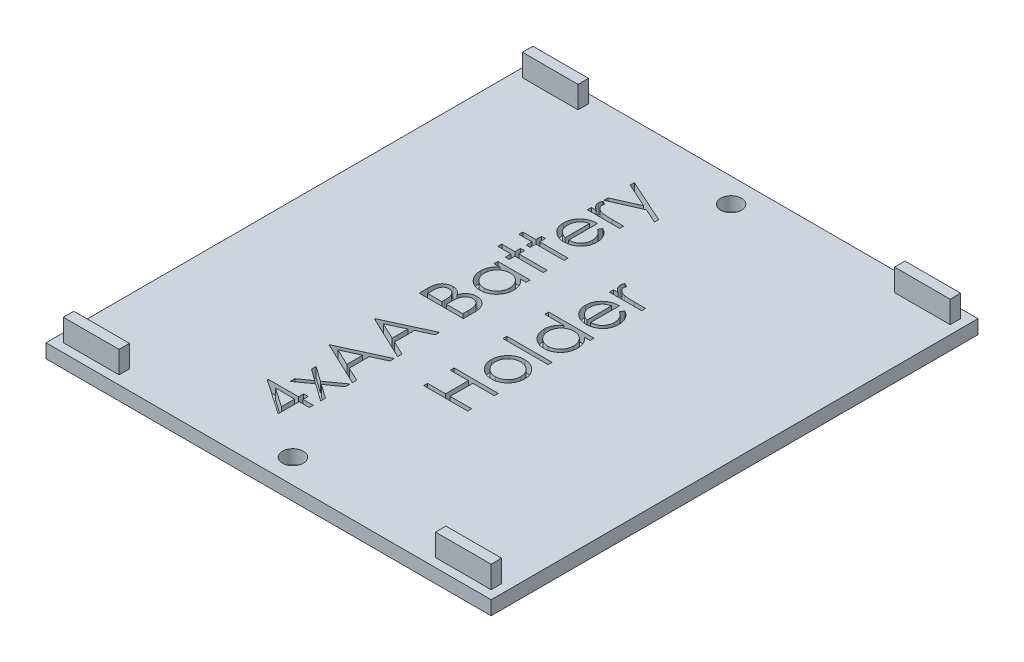
from build123d import *

# Parameters (mm, degrees)
SKETCH1_W               = 64
SKETCH1_H               = 70
BASE_DEPTH              = 2
SKETCH2_W               = 8
SKETCH2_H               = 1.5
BOSS_EXTRUDE2_DEPTH     = 3.175
MIRROR3_COPY_1_SKETCH_W = 8
MIRROR3_COPY_1_SKETCH_H = 1.5
MIRROR3_COPY_1_DEPTH    = 3.175
MIRROR3_COPY_2_SKETCH_W = 8
MIRROR3_COPY_2_SKETCH_H = 1.5
MIRROR3_COPY_2_DEPTH    = 3.175
SKETCH4_W               = 6.512820513
SKETCH4_H               = 0.569871795
LETTERS_DEPTH           = 1.5
SKETCH7_R               = 1.5
CUT_EXTRUDE3_DEPTH      = 48.529786854


with BuildPart() as part:
    # Sketch1 → Base (new body)
    with BuildSketch(Plane(origin=(0, 0, 0), x_dir=(1, 0, 0), z_dir=(0, 1, 0))):
        Rectangle(SKETCH1_W, SKETCH1_H)
    extrude(amount=BASE_DEPTH)

    # Sketch2 → Boss-Extrude2 (add)
    with BuildSketch(Plane(origin=(0, 2, 0), x_dir=(1, 0, 0), z_dir=(0, 1, 0))):
        with Locations((-26.75, 33)):
            Rectangle(SKETCH2_W, SKETCH2_H)
    boss_extrude2 = extrude(amount=BOSS_EXTRUDE2_DEPTH)

    # Mirror2: Boss-Extrude2 across plane
    add(boss_extrude2.mirror(Plane.XY))

    # Mirror3 copy 1 sketch → Mirror3 copy 1 (add)
    with BuildSketch(Plane(origin=(0, 2, 0), x_dir=(-1, 0, 0), z_dir=(0, 1, 0))):
        with Locations((-26.75, 33)):
            Rectangle(MIRROR3_COPY_1_SKETCH_W, MIRROR3_COPY_1_SKETCH_H)
    extrude(amount=MIRROR3_COPY_1_DEPTH)

    # Mirror3 copy 2 sketch → Mirror3 copy 2 (add)
    with BuildSketch(Plane(origin=(0, 2, 0), x_dir=(-1, 0, 0), z_dir=(0, 1, 0))):
        with Locations((-26.75, -33)):
            Rectangle(MIRROR3_COPY_2_SKETCH_W, MIRROR3_COPY_2_SKETCH_H)
    extrude(amount=MIRROR3_COPY_2_DEPTH)

    # Sketch4 → Letters (cut)
    # profile 1 of 17: a face of its own
    with BuildSketch(Plane(origin=(-14.943623663, 2, 1.769971189), x_dir=(1, 0, 0), z_dir=(0, 1, 0))):
        Polygon((3.43080315, -21.914053251), (3.43080315, -21.798298042), (7.826956997, -21.798298042), (7.826956997, -21.065605735), (8.478239048, -21.065605735), (8.478239048, -21.798298042), (9.943623663, -21.798298042), (9.943623663, -22.368169837), (8.478239048, -22.368169837), (8.478239048, -25.380349324), align=None)
        Polygon((7.826956997, -22.368169837), (5.069184561, -22.368169837), (7.826956997, -24.260958299), align=None, mode=Mode.SUBTRACT)
    # profile 2 of 17: a face of its own
    with BuildSketch(Plane(origin=(-14.943623663, 2, 1.769971189), x_dir=(1, 0, 0), z_dir=(0, 1, 0))):
        Polygon((5.303239048, -20.49573394), (5.303239048, -19.817739148), (6.977237445, -18.623298042), (5.303239048, -17.428856936), (5.303239048, -16.750862145), (7.451706596, -18.283664629), (9.943623663, -16.506631376), (9.943623663, -17.184626167), (7.927447782, -18.623298042), (9.943623663, -20.061969917), (9.943623663, -20.739964709), (7.451706596, -18.96165942), align=None)
    # profile 3 of 17: a face of its own
    with BuildSketch(Plane(origin=(-14.943623663, 2, 1.769971189), x_dir=(1, 0, 0), z_dir=(0, 1, 0))):
        Polygon((3.593623663, -13.087400606), (9.943623663, -10.156631376), (9.943623663, -10.776112545), (7.908367253, -11.714874565), (7.908367253, -14.59349035), (9.943623663, -15.55896511), (9.943623663, -16.18099035), (3.593623663, -13.168810863), align=None)
        Polygon((4.831313968, -13.134465911), (7.257085202, -14.284385783), (7.257085202, -12.015074885), align=None, mode=Mode.SUBTRACT)
    # profile 4 of 17: a face of its own
    with BuildSketch(Plane(origin=(-14.943623663, 2, 1.769971189), x_dir=(1, 0, 0), z_dir=(0, 1, 0))):
        Polygon((3.593623663, -6.574580093), (9.943623663, -3.643810863), (9.943623663, -4.263292033), (7.908367253, -5.202054052), (7.908367253, -8.080669837), (9.943623663, -9.046144597), (9.943623663, -9.668169837), (3.593623663, -6.65599035), align=None)
        Polygon((4.831313968, -6.621645398), (7.257085202, -7.77156527), (7.257085202, -5.502254372), align=None, mode=Mode.SUBTRACT)
    # profile 5 of 17: a face of its own
    with BuildSketch(Plane(origin=(-14.943623663, 2, 1.769971189), x_dir=(1, 0, 0), z_dir=(0, 1, 0))):
        with BuildLine():
            Line((3.593623663, -0.224580093), (3.593623663, 1.014382246))
            add(Edge.make_bspline(
                [(3.593623663, 1.014382246), (3.593937505, 1.075032013), (3.594545808, 1.192586356), (3.604199138, 1.363514344), (3.617032327, 1.52366793), (3.638559312, 1.672764102), (3.660879955, 1.811773006), (3.693641316, 1.93928341), (3.729827432, 2.056363373), (3.785504684, 2.196952443), (3.871972157, 2.356470008), (4.000211636, 2.527921542), (4.153960416, 2.676957677), (4.329169279, 2.803682568), (4.521918882, 2.90538199), (4.728062157, 2.978026234), (4.944130988, 3.024695663), (5.09226615, 3.029434985), (5.167131275, 3.031830163)],
                knots=[0, 0, 0, 0, 1.00128172, 1.940733171, 2.826250472, 3.653024905, 4.427672124, 5.149348099, 5.824709082, 6.450061444, 7.643590664, 8.808605388, 9.972104426, 11.165284501, 12.367876273, 13.557044126, 14.765369432, 16, 16, 16, 16], degree=3))
            add(Edge.make_bspline(
                [(5.167131275, 3.031830163), (5.237254972, 3.029835155), (5.375054648, 3.025914776), (5.576255016, 2.988883444), (5.767584804, 2.930109428), (5.948880263, 2.848881366), (6.116766562, 2.744223554), (6.270723634, 2.618828784), (6.40493275, 2.46816797), (6.479934982, 2.355232116), (6.518032718, 2.29786582)],
                knots=[0, 0, 0, 0, 1.044641374, 2.052818814, 3.038628718, 4.023282556, 5.005660861, 5.98021751, 6.974042014, 8, 8, 8, 8], degree=3))
            add(Edge.make_bspline(
                [(6.518032718, 2.29786582), (6.545736755, 2.36999563), (6.598741441, 2.507997825), (6.69230658, 2.698018531), (6.794441874, 2.8611364), (6.904255556, 3.000537857), (7.024368761, 3.119132412), (7.155757354, 3.221842155), (7.298313772, 3.310636729), (7.451514075, 3.386200297), (7.614059515, 3.445556422), (7.78396476, 3.489182351), (7.960578477, 3.514988037), (8.080432082, 3.518508328), (8.141149705, 3.520291701)],
                knots=[0, 0, 0, 0, 1.272586185, 2.434772614, 3.483318042, 4.437947805, 5.351807173, 6.25737843, 7.180033415, 8.1141739, 9.066731021, 10.025721652, 10.999834114, 12, 12, 12, 12], degree=3))
            add(Edge.make_bspline(
                [(8.141149705, 3.520291701), (8.203138425, 3.518519811), (8.325102969, 3.515033567), (8.504269396, 3.489301514), (8.675505755, 3.445762469), (8.839840724, 3.385687144), (8.99692975, 3.307819523), (9.146203753, 3.211687586), (9.287973294, 3.098640832), (9.422488579, 2.970879728), (9.545574294, 2.828499973), (9.6513865, 2.671588318), (9.742369917, 2.50444338), (9.816445371, 2.324928368), (9.873594534, 2.133501548), (9.913411782, 1.930269441), (9.940285601, 1.715566738), (9.942492096, 1.568227968), (9.943623663, 1.492667503)],
                knots=[0, 0, 0, 0, 0.978680899, 1.925582087, 2.851223405, 3.764209995, 4.683484765, 5.614004905, 6.562443559, 7.542772147, 8.539900013, 9.527881485, 10.525548727, 11.540192123, 12.58875426, 13.674701727, 14.807505862, 16, 16, 16, 16], degree=3))
            Line((9.943623663, 1.492667503), (9.943623663, -0.224580093))
            Line((9.943623663, -0.224580093), (3.593623663, -0.224580093))
        make_face()
        with BuildLine():
            Line((4.244905715, 0.345291701), (6.280162125, 0.345291701))
            Line((6.280162125, 0.345291701), (6.280162125, 0.728174314))
            add(Edge.make_bspline(
                [(6.280162125, 0.728174314), (6.27943655, 0.784142842), (6.278034593, 0.892285446), (6.274018639, 1.048894399), (6.262773622, 1.194264081), (6.251531816, 1.328143531), (6.233253688, 1.450322025), (6.211496381, 1.560528548), (6.188486516, 1.660493784), (6.149350985, 1.775769975), (6.091531512, 1.906549207), (6.001713294, 2.045874071), (5.894818274, 2.169270566), (5.770322499, 2.272222394), (5.634724709, 2.3572245), (5.489215326, 2.416771148), (5.336722536, 2.456469125), (5.231833895, 2.460109877), (5.178579593, 2.461958368)],
                knots=[0, 0, 0, 0, 1.156917035, 2.235399477, 3.236897345, 4.169954739, 5.01148057, 5.788325709, 6.491867502, 7.129259015, 8.302032419, 9.437271567, 10.542795419, 11.662606952, 12.764338259, 13.836858145, 14.901724648, 16, 16, 16, 16], degree=3))
            add(Edge.make_bspline(
                [(5.178579593, 2.461958368), (5.143331073, 2.461019818), (5.074187252, 2.45917875), (4.973064059, 2.443552627), (4.878045349, 2.418234161), (4.78821918, 2.383946133), (4.70581795, 2.337103598), (4.626904313, 2.282806946), (4.556204811, 2.215770021), (4.490315694, 2.140012343), (4.431345155, 2.053332047), (4.382497203, 1.953861605), (4.338224729, 1.844172479), (4.305451132, 1.721288744), (4.276631893, 1.587756592), (4.258524571, 1.441767949), (4.246872338, 1.284247913), (4.245575877, 1.175106313), (4.244905715, 1.118689137)],
                knots=[0, 0, 0, 0, 0.911708768, 1.788416306, 2.640049961, 3.452993646, 4.268229297, 5.087074648, 5.92553149, 6.781184137, 7.681934069, 8.628939405, 9.643570426, 10.73771997, 11.914765019, 13.176320755, 14.540391495, 16, 16, 16, 16], degree=3))
            Line((4.244905715, 1.118689137), (4.244905715, 0.345291701))
        make_face(mode=Mode.SUBTRACT)
        with BuildLine():
            Line((6.931444176, 0.345291701), (9.292341612, 0.345291701))
            Line((9.292341612, 0.345291701), (9.292341612, 1.156850195))
            add(Edge.make_bspline(
                [(9.292341612, 1.156850195), (9.291576156, 1.214935599), (9.290100841, 1.326887558), (9.28664092, 1.488654245), (9.273552564, 1.638195702), (9.261478615, 1.775983681), (9.240832681, 1.90165249), (9.221348288, 2.016168782), (9.192425097, 2.117652693), (9.152673574, 2.236412347), (9.089036321, 2.369158191), (8.996062895, 2.514225505), (8.881319334, 2.640721954), (8.750820264, 2.749307347), (8.609319449, 2.838916729), (8.458666742, 2.903219936), (8.301792052, 2.943180243), (8.194804951, 2.948001827), (8.141149705, 2.950419907)],
                knots=[0, 0, 0, 0, 1.160376723, 2.23647316, 3.230273494, 4.158083346, 4.997711197, 5.773399541, 6.476071462, 7.102777513, 8.27340052, 9.405620712, 10.53304798, 11.669441455, 12.787990954, 13.865552736, 14.929550474, 16, 16, 16, 16], degree=3))
            add(Edge.make_bspline(
                [(8.141149705, 2.950419907), (8.107596779, 2.949920508), (8.041032138, 2.948929768), (7.943223973, 2.933920287), (7.848432394, 2.912206324), (7.756262389, 2.883608411), (7.668263675, 2.843630071), (7.584098778, 2.794619976), (7.502072221, 2.738519214), (7.39703011, 2.651966351), (7.277506758, 2.524236404), (7.161931491, 2.342717897), (7.067218679, 2.137464505), (7.027178156, 1.988248325), (7.006494256, 1.911167102)],
                knots=[0, 0, 0, 0, 0.723302347, 1.434937762, 2.129609326, 2.821140842, 3.513216847, 4.209993937, 4.920569932, 5.655069131, 7.14393391, 8.6716197, 10.280644748, 12, 12, 12, 12], degree=3))
            add(Edge.make_bspline(
                [(7.006494256, 1.911167102), (7.000225747, 1.880271457), (6.986634325, 1.813283325), (6.972287492, 1.704049572), (6.95950574, 1.579343067), (6.950051212, 1.438875847), (6.940278483, 1.282470192), (6.936477879, 1.109792068), (6.931943507, 0.921546654), (6.931614877, 0.790931922), (6.931444176, 0.723086173)],
                knots=[0, 0, 0, 0, 0.634451884, 1.375622551, 2.216452059, 3.157844607, 4.20941857, 5.370758133, 6.634282058, 8, 8, 8, 8], degree=3))
            Line((6.931444176, 0.723086173), (6.931444176, 0.345291701))
        make_face(mode=Mode.SUBTRACT)
    # profile 6 of 17: a face of its own
    with BuildSketch(Plane(origin=(-14.943623663, 2, 1.769971189), x_dir=(1, 0, 0), z_dir=(0, 1, 0))):
        with BuildLine():
            Line((5.303239048, 9.381830163), (9.943623663, 9.381830163))
            Line((9.943623663, 9.381830163), (9.943623663, 8.811958368))
            Line((9.943623663, 8.811958368), (9.140969416, 8.811958368))
            add(Edge.make_bspline(
                [(9.140969416, 8.811958368), (9.213492983, 8.747598242), (9.355234107, 8.621811867), (9.542106959, 8.413704558), (9.693422684, 8.190368578), (9.817407586, 7.957408086), (9.910164545, 7.712541172), (9.976211859, 7.457047679), (10.018646129, 7.190683514), (10.022885553, 7.008797974), (10.02503392, 6.916625836)],
                knots=[0, 0, 0, 0, 1.074325654, 2.099677833, 3.090439787, 4.057542011, 5.018572219, 5.985274637, 6.979019747, 8, 8, 8, 8], degree=3))
            add(Edge.make_bspline(
                [(10.02503392, 6.916625836), (10.02280893, 6.834678263), (10.018421152, 6.673074019), (9.984380972, 6.435349837), (9.929715416, 6.20658247), (9.853695231, 5.986555745), (9.75285574, 5.776693424), (9.632130904, 5.575198677), (9.488365398, 5.383115365), (9.324012833, 5.203371287), (9.145496213, 5.037850372), (8.955095007, 4.892596349), (8.753632541, 4.771487189), (8.543659533, 4.670213614), (8.323559608, 4.592205961), (8.094093889, 4.537825225), (7.85553369, 4.5038247), (7.693083412, 4.499438735), (7.610711003, 4.497214778)],
                knots=[0, 0, 0, 0, 1.033919861, 2.038935746, 3.024066025, 3.998881131, 4.97069526, 5.957263378, 6.95902576, 7.993208707, 9.027059324, 10.027763471, 11.009749337, 11.988697705, 12.965288445, 13.950418724, 14.960734635, 16, 16, 16, 16], degree=3))
            add(Edge.make_bspline(
                [(7.610711003, 4.497214778), (7.530041141, 4.499488026), (7.370561175, 4.503982115), (7.13601268, 4.537461528), (6.910100979, 4.593760644), (6.693553382, 4.672768882), (6.486107862, 4.774082143), (6.287617702, 4.897323101), (6.097536081, 5.042500656), (5.92033257, 5.20987288), (5.756646598, 5.391183106), (5.614390187, 5.585146089), (5.491532476, 5.786936899), (5.39418974, 5.999685504), (5.315433222, 6.220242966), (5.260944837, 6.450572789), (5.22883684, 6.689716653), (5.224187253, 6.852077974), (5.221828791, 6.93443433)],
                knots=[0, 0, 0, 0, 1.020392517, 2.01726096, 2.990465484, 3.961182959, 4.928053699, 5.906110375, 6.912531644, 7.948652711, 8.985773172, 9.998621852, 10.987621588, 11.969261332, 12.953316658, 13.946091881, 14.958173133, 16, 16, 16, 16], degree=3))
            add(Edge.make_bspline(
                [(5.221828791, 6.93443433), (5.224440189, 7.029137994), (5.229561017, 7.214847411), (5.272088028, 7.48652216), (5.344153349, 7.743413224), (5.441504795, 7.98824775), (5.573578097, 8.217655653), (5.735521588, 8.434492721), (5.934030582, 8.63414573), (6.084605027, 8.751662182), (6.161862846, 8.811958368)],
                knots=[0, 0, 0, 0, 1.039007978, 2.037445607, 3.008437381, 3.96246474, 4.921201921, 5.904967172, 6.925065498, 8, 8, 8, 8], degree=3))
            Line((6.161862846, 8.811958368), (5.303239048, 8.811958368))
            Line((5.303239048, 8.811958368), (5.303239048, 9.381830163))
        make_face()
        with BuildLine():
            add(Edge.make_bspline(
                [(5.791700586, 6.942066541), (5.794667009, 6.858766607), (5.800522254, 6.694345785), (5.846157483, 6.452940027), (5.922285953, 6.222054541), (6.025791529, 6.002048356), (6.158411712, 5.799056485), (6.314662774, 5.614453935), (6.497182174, 5.453932723), (6.699438066, 5.315884868), (6.917464945, 5.205063312), (7.145304617, 5.126642139), (7.37901403, 5.075017599), (7.537512181, 5.069737132), (7.617071179, 5.067086573)],
                knots=[0, 0, 0, 0, 1.031130969, 2.035288524, 3.029955243, 4.035265425, 5.037320146, 6.024362013, 7.021230137, 8.037832003, 9.049975902, 10.039737725, 11.016035826, 12, 12, 12, 12], degree=3))
            add(Edge.make_bspline(
                [(7.617071179, 5.067086573), (7.696151093, 5.070483677), (7.854000955, 5.077264568), (8.087690308, 5.125511858), (8.315018545, 5.207516707), (8.534797458, 5.318188409), (8.739029616, 5.457860982), (8.924827274, 5.618229528), (9.083522447, 5.803720248), (9.216462346, 6.008526996), (9.323782373, 6.227364682), (9.398473247, 6.457472327), (9.446691717, 6.694556672), (9.45232429, 6.855760003), (9.455162125, 6.9369784)],
                knots=[0, 0, 0, 0, 0.979154007, 1.954470061, 2.941101473, 3.965068436, 4.993389179, 5.998216918, 6.996159742, 8.005560442, 9.015493761, 10.005250788, 10.994993882, 12, 12, 12, 12], degree=3))
            add(Edge.make_bspline(
                [(9.455162125, 6.9369784), (9.452115684, 7.019420106), (9.446056615, 7.183388483), (9.400679576, 7.425780007), (9.32286612, 7.660203795), (9.218292884, 7.885060707), (9.088044227, 8.094329082), (8.935558235, 8.281513704), (8.759437633, 8.441664554), (8.563630344, 8.575001855), (8.350335697, 8.680744849), (8.123478696, 8.758062776), (7.882598867, 8.803268515), (7.717752316, 8.809021699), (7.633607638, 8.811958368)],
                knots=[0, 0, 0, 0, 1.01787422, 2.024450869, 3.03297362, 4.061474925, 5.080076323, 6.069755756, 7.033548292, 8.009625779, 8.9862229, 9.964937832, 10.961217871, 12, 12, 12, 12], degree=3))
            add(Edge.make_bspline(
                [(7.633607638, 8.811958368), (7.569494717, 8.810217277), (7.443300199, 8.806790259), (7.258011703, 8.780609083), (7.0806948, 8.738962288), (6.911163064, 8.680277094), (6.750353822, 8.603185764), (6.597112428, 8.510207674), (6.452235888, 8.399707787), (6.317719173, 8.273464895), (6.195025449, 8.135279456), (6.085507469, 7.989057933), (5.995539267, 7.83306792), (5.921078675, 7.669932725), (5.861825645, 7.499369304), (5.822296544, 7.319989751), (5.795154247, 7.133700732), (5.792863928, 7.006617174), (5.791700586, 6.942066541)],
                knots=[0, 0, 0, 0, 1.050140795, 2.067009409, 3.05949893, 4.030605086, 5.00011959, 5.97591094, 6.962425594, 7.979863591, 8.993523472, 9.986985069, 10.967611495, 11.937549037, 12.921786183, 13.919465291, 14.943216303, 16, 16, 16, 16], degree=3))
        make_face(mode=Mode.SUBTRACT)
    # profile 7 of 17: a face of its own
    with BuildSketch(Plane(origin=(-14.943623663, 2, 1.769971189), x_dir=(1, 0, 0), z_dir=(0, 1, 0))):
        Polygon((3.43080315, 11.25426606), (3.43080315, 11.824137855), (5.303239048, 11.824137855), (5.303239048, 12.638240419), (5.873110843, 12.638240419), (5.873110843, 11.824137855), (9.943623663, 11.824137855), (9.943623663, 11.25426606), (5.873110843, 11.25426606), (5.873110843, 10.440163496), (5.303239048, 10.440163496), (5.303239048, 11.25426606), align=None)
    # profile 8 of 17: a face of its own
    with BuildSketch(Plane(origin=(-14.943623663, 2, 1.769971189), x_dir=(1, 0, 0), z_dir=(0, 1, 0))):
        Polygon((3.43080315, 14.266445548), (3.43080315, 14.836317342), (5.303239048, 14.836317342), (5.303239048, 15.650419907), (5.873110843, 15.650419907), (5.873110843, 14.836317342), (9.943623663, 14.836317342), (9.943623663, 14.266445548), (5.873110843, 14.266445548), (5.873110843, 13.452342983), (5.303239048, 13.452342983), (5.303239048, 14.266445548), align=None)
    # profile 9 of 17: a face of its own
    with BuildSketch(Plane(origin=(-14.943623663, 2, 1.769971189), x_dir=(1, 0, 0), z_dir=(0, 1, 0))):
        with BuildLine():
            Line((8.478239048, 20.517226798), (8.744094416, 21.02349683))
            add(Edge.make_bspline(
                [(8.744094416, 21.02349683), (8.815638925, 20.983132127), (8.954836207, 20.904598402), (9.146087265, 20.770092842), (9.317115506, 20.627801195), (9.465182278, 20.47339409), (9.595943623, 20.311524469), (9.708732595, 20.139117921), (9.805584315, 19.957581698), (9.884945262, 19.764916268), (9.947335425, 19.561352425), (9.993410987, 19.345708948), (10.020130434, 19.116967648), (10.023373372, 18.960325915), (10.02503392, 18.880117423)],
                knots=[0, 0, 0, 0, 1.120611642, 2.180266485, 3.186550691, 4.152466804, 5.095166165, 6.022949561, 6.960161436, 7.899497276, 8.862391909, 9.862399089, 10.905440174, 12, 12, 12, 12], degree=3))
            add(Edge.make_bspline(
                [(10.02503392, 18.880117423), (10.022952616, 18.790959835), (10.018892595, 18.61703921), (9.983890553, 18.363874239), (9.926790699, 18.125514444), (9.847024656, 17.901973184), (9.742835044, 17.69379805), (9.615908699, 17.500574716), (9.466896778, 17.321289207), (9.294511869, 17.161583033), (9.110024079, 17.017830943), (8.917817546, 16.890897019), (8.718557901, 16.785269796), (8.513430696, 16.698035348), (8.302902063, 16.629223898), (8.085766278, 16.580325422), (7.862884348, 16.552397852), (7.712125173, 16.548099058), (7.636151708, 16.545932727)],
                knots=[0, 0, 0, 0, 1.14524686, 2.234044844, 3.276713788, 4.290115724, 5.276966211, 6.260758605, 7.254862358, 8.264742877, 9.274005885, 10.257798278, 11.220590477, 12.167824544, 13.118936889, 14.062732937, 15.023735098, 16, 16, 16, 16], degree=3))
            add(Edge.make_bspline(
                [(7.636151708, 16.545932727), (7.564859659, 16.547854312), (7.423568231, 16.55166264), (7.214443601, 16.575667068), (7.01119198, 16.618208971), (6.813644481, 16.676586016), (6.622131867, 16.751971849), (6.43653758, 16.844196018), (6.257059112, 16.953402189), (6.143841998, 17.037716897), (6.086812766, 17.080187535)],
                knots=[0, 0, 0, 0, 1.024358464, 2.0301432, 3.019427413, 4.004406732, 4.986367066, 5.972626655, 6.978780325, 8, 8, 8, 8], degree=3))
            add(Edge.make_bspline(
                [(6.086812766, 17.080187535), (6.017993899, 17.137615155), (5.882757229, 17.250466769), (5.70668112, 17.443319463), (5.556063061, 17.649331207), (5.433188551, 17.870574231), (5.338678625, 18.106675865), (5.271454965, 18.356418315), (5.229625333, 18.62049186), (5.22446715, 18.801517165), (5.221828791, 18.89410981)],
                knots=[0, 0, 0, 0, 1.030811313, 2.025658015, 2.997072178, 3.962767568, 4.930766827, 5.917075773, 6.934604948, 8, 8, 8, 8], degree=3))
            add(Edge.make_bspline(
                [(5.221828791, 18.89410981), (5.224273119, 18.989270223), (5.229068333, 19.17595326), (5.27392138, 19.448077087), (5.344186372, 19.706071974), (5.446559129, 19.947808821), (5.573457155, 20.177012436), (5.733850318, 20.388407725), (5.919500635, 20.587797624), (6.062422456, 20.703733901), (6.135150106, 20.762729602)],
                knots=[0, 0, 0, 0, 1.056389096, 2.072394598, 3.055233004, 4.020130009, 4.981825462, 5.957811105, 6.960805292, 8, 8, 8, 8], degree=3))
            add(Edge.make_bspline(
                [(6.135150106, 20.762729602), (6.189948032, 20.80287419), (6.299179133, 20.882896152), (6.477289661, 20.983130176), (6.663636025, 21.070138593), (6.861230421, 21.139685536), (7.067731659, 21.19600006), (7.28461599, 21.236743145), (7.51181883, 21.260636596), (7.66662558, 21.265333233), (7.74554674, 21.267727599)],
                knots=[0, 0, 0, 0, 0.94817472, 1.890038105, 2.849395472, 3.817997239, 4.812318967, 5.836947057, 6.897266129, 8, 8, 8, 8], degree=3))
            Line((7.74554674, 21.267727599), (7.74554674, 17.115804522))
            add(Edge.make_bspline(
                [(7.74554674, 17.115804522), (7.806689011, 17.118597808), (7.926922821, 17.124090692), (8.102855527, 17.149699595), (8.270447162, 17.190065227), (8.428440681, 17.246796241), (8.578899627, 17.315497517), (8.720707894, 17.39965446), (8.853219567, 17.500056223), (8.977619945, 17.612044277), (9.088401612, 17.736698579), (9.187555549, 17.867840134), (9.270659989, 18.007347031), (9.338114931, 18.154119268), (9.390922105, 18.307919507), (9.426968008, 18.468796204), (9.451110902, 18.636432786), (9.453795437, 18.750706904), (9.455162125, 18.808883448)],
                knots=[0, 0, 0, 0, 1.094153842, 2.151609401, 3.174256925, 4.172055639, 5.149267565, 6.128595816, 7.11444997, 8.118368179, 9.117203808, 10.09244225, 11.054858984, 12.015122123, 12.976791628, 13.957293641, 14.960065497, 16, 16, 16, 16], degree=3))
            add(Edge.make_bspline(
                [(9.455162125, 18.808883448), (9.45406782, 18.865765869), (9.451896509, 18.978631504), (9.430480609, 19.14667193), (9.396538265, 19.312281418), (9.347650967, 19.473815512), (9.290404601, 19.628920054), (9.223025997, 19.773348842), (9.146206762, 19.905192453), (9.058911323, 20.028898318), (8.951776893, 20.148237328), (8.819368102, 20.268496367), (8.660183165, 20.39459961), (8.54116933, 20.474812876), (8.478239048, 20.517226798)],
                knots=[0, 0, 0, 0, 0.991168677, 1.966668791, 2.94808785, 3.9350306, 4.905702032, 5.828266021, 6.709360349, 7.562606342, 8.463112863, 9.498839253, 10.677475166, 12, 12, 12, 12], degree=3))
        make_face()
        with BuildLine():
            add(Edge.make_bspline(
                [(7.175674945, 20.697855804), (7.100048815, 20.677082109), (6.954871215, 20.637203363), (6.75390558, 20.552274645), (6.574269929, 20.458933184), (6.418949407, 20.346568432), (6.280783152, 20.220499492), (6.161971797, 20.072869714), (6.052465649, 19.910081972), (5.961273096, 19.728893863), (5.886334769, 19.536450543), (5.831231933, 19.336707481), (5.798840835, 19.13133771), (5.794091857, 18.993016192), (5.791700586, 18.923366621)],
                knots=[0, 0, 0, 0, 1.155085888, 2.217389643, 3.210301801, 4.133263417, 5.03575695, 5.95948047, 6.920061569, 7.923798377, 8.943125483, 9.960783337, 10.973185325, 12, 12, 12, 12], degree=3))
            add(Edge.make_bspline(
                [(5.791700586, 18.923366621), (5.792797392, 18.866485437), (5.794965548, 18.754043293), (5.815962612, 18.588459866), (5.849702564, 18.429028905), (5.899311968, 18.276226305), (5.959676808, 18.129038469), (6.033877411, 17.987571752), (6.123587238, 17.853644735), (6.192116106, 17.769940539), (6.226736644, 17.72765348)],
                knots=[0, 0, 0, 0, 1.048823158, 2.073302879, 3.073550078, 4.050623576, 5.03253758, 6.005186856, 6.992227572, 8, 8, 8, 8], degree=3))
            add(Edge.make_bspline(
                [(6.226736644, 17.72765348), (6.254119167, 17.697362351), (6.30953472, 17.636060487), (6.405064062, 17.554236768), (6.50813463, 17.475309189), (6.623245548, 17.405170535), (6.747058724, 17.338514156), (6.880477593, 17.277772912), (7.024065319, 17.222544161), (7.12417164, 17.191540916), (7.175674945, 17.175590179)],
                knots=[0, 0, 0, 0, 0.879905587, 1.780714457, 2.708106151, 3.677566983, 4.684151534, 5.740052498, 6.837288539, 8, 8, 8, 8], degree=3))
            Line((7.175674945, 17.175590179), (7.175674945, 20.697855804))
        make_face(mode=Mode.SUBTRACT)
    # profile 10 of 17: a face of its own
    with BuildSketch(Plane(origin=(-14.943623663, 2, 1.769971189), x_dir=(1, 0, 0), z_dir=(0, 1, 0))):
        with BuildLine():
            Line((5.303239048, 22.244650676), (5.303239048, 22.814522471))
            Line((5.303239048, 22.814522471), (5.986321981, 22.814522471))
            add(Edge.make_bspline(
                [(5.986321981, 22.814522471), (5.922692219, 22.856566585), (5.801000795, 22.936975628), (5.640272101, 23.071250583), (5.505675407, 23.207321239), (5.399777493, 23.348760562), (5.31974453, 23.494181848), (5.263507873, 23.642358839), (5.228633812, 23.793653878), (5.22410017, 23.895572217), (5.221828791, 23.946633849)],
                knots=[0, 0, 0, 0, 1.280091057, 2.448164201, 3.510831157, 4.48793739, 5.405868014, 6.289422536, 7.142991551, 8, 8, 8, 8], degree=3))
            add(Edge.make_bspline(
                [(5.221828791, 23.946633849), (5.223988747, 23.986233041), (5.228432995, 24.067710953), (5.259658349, 24.191050794), (5.309511333, 24.318129629), (5.356392879, 24.400030817), (5.380833199, 24.442727599)],
                knots=[0, 0, 0, 0, 0.901110191, 1.854092781, 2.881294221, 4, 4, 4, 4], degree=3))
            Line((5.380833199, 24.442727599), (5.874382878, 24.129806926))
            add(Edge.make_bspline(
                [(5.874382878, 24.129806926), (5.862154109, 24.102394845), (5.838941566, 24.050361467), (5.811469633, 23.974243897), (5.795293614, 23.9040649), (5.792843027, 23.859354444), (5.791700586, 23.838510852)],
                knots=[0, 0, 0, 0, 1.180555205, 2.24091978, 3.179933427, 4, 4, 4, 4], degree=3))
            add(Edge.make_bspline(
                [(5.791700586, 23.838510852), (5.794724784, 23.79276672), (5.800893271, 23.69946195), (5.850079764, 23.56293453), (5.927264592, 23.42926635), (6.015155291, 23.324131697), (6.099581993, 23.242440101), (6.173473976, 23.183689577), (6.257095864, 23.130960107), (6.347215485, 23.079811122), (6.446094586, 23.032289852), (6.553894475, 22.989822617), (6.669724982, 22.950107577), (6.750264633, 22.927741897), (6.791520298, 22.916285291)],
                knots=[0, 0, 0, 0, 1.125322384, 2.295331465, 3.535939348, 4.916963136, 5.656144286, 6.429838446, 7.238666481, 8.090384391, 8.983239461, 9.940052224, 10.944811494, 12, 12, 12, 12], degree=3))
            add(Edge.make_bspline(
                [(6.791520298, 22.916285291), (6.828306848, 22.907684539), (6.910194857, 22.888538996), (7.046950996, 22.870420826), (7.208419934, 22.851798302), (7.394789248, 22.839080993), (7.606775347, 22.827067798), (7.843463722, 22.820431214), (8.105504914, 22.814733623), (8.288277618, 22.814595101), (8.384108439, 22.814522471)],
                knots=[0, 0, 0, 0, 0.566841273, 1.261806378, 2.068780918, 3.007109044, 4.065315289, 5.256255371, 6.561408263, 8, 8, 8, 8], degree=3))
            Line((8.384108439, 22.814522471), (9.943623663, 22.814522471))
            Line((9.943623663, 22.814522471), (9.943623663, 22.244650676))
            Line((9.943623663, 22.244650676), (5.303239048, 22.244650676))
        make_face()
    # profile 11 of 17: a face of its own
    with BuildSketch(Plane(origin=(-14.943623663, 2, 1.769971189), x_dir=(1, 0, 0), z_dir=(0, 1, 0))):
        Polygon((5.303239048, 24.605548112), (5.303239048, 25.21994114), (8.857305554, 26.790904682), (5.303239048, 28.386036894), (5.303239048, 29.001701958), (11.653239048, 26.152342983), (11.653239048, 25.536677919), (9.548020699, 26.481800115), align=None)
    # profile 12 of 17: a face of its own
    with BuildSketch(Plane(origin=(-14.943623663, 2, 1.769971189), x_dir=(1, 0, 0), z_dir=(0, 1, 0))):
        Polygon((15.421187766, -11.41849035), (15.421187766, -10.848618555), (18.026315971, -10.848618555), (18.026315971, -7.592208299), (15.421187766, -7.592208299), (15.421187766, -7.022336504), (21.771187766, -7.022336504), (21.771187766, -7.592208299), (18.677598022, -7.592208299), (18.677598022, -10.848618555), (21.771187766, -10.848618555), (21.771187766, -11.41849035), align=None)
    # profile 13 of 17: a face of its own
    with BuildSketch(Plane(origin=(-14.943623663, 2, 1.769971189), x_dir=(1, 0, 0), z_dir=(0, 1, 0))):
        with BuildLine():
            add(Edge.make_bspline(
                [(17.049392894, -3.315625767), (17.051246897, -3.228555886), (17.054882142, -3.057833129), (17.093735009, -2.80781025), (17.153148084, -2.569149789), (17.235283632, -2.340937697), (17.345378028, -2.126096704), (17.476749171, -1.921497447), (17.632383305, -1.727700874), (17.7527758, -1.611544806), (17.813886083, -1.552584901)],
                knots=[0, 0, 0, 0, 1.054011418, 2.066658804, 3.057071809, 4.030435133, 4.997543892, 5.974964718, 6.972108034, 8, 8, 8, 8], degree=3))
            add(Edge.make_bspline(
                [(17.813886083, -1.552584901), (17.872331457, -1.501817642), (17.988091127, -1.401265609), (18.175789167, -1.272332091), (18.370171921, -1.161258689), (18.573820643, -1.072244459), (18.784957546, -1.002058774), (19.004308338, -0.952228153), (19.231388596, -0.922588286), (19.385609845, -0.918591474), (19.463715811, -0.916567273)],
                knots=[0, 0, 0, 0, 1.025258237, 2.030674902, 3.01204498, 3.988269485, 4.97094183, 5.956517959, 6.965070386, 8, 8, 8, 8], degree=3))
            add(Edge.make_bspline(
                [(19.463715811, -0.916567273), (19.542274487, -0.918347699), (19.697510094, -0.921865905), (19.926145229, -0.955146466), (20.147841551, -1.006910007), (20.361670895, -1.080990628), (20.568286882, -1.175983198), (20.766787064, -1.291899159), (20.957563077, -1.42955195), (21.138994984, -1.585587773), (21.306210831, -1.758039034), (21.451949263, -1.945121189), (21.576811171, -2.143157793), (21.677388668, -2.354782163), (21.756690553, -2.578061746), (21.812389154, -2.813478141), (21.846065352, -3.060665626), (21.850389835, -3.229443584), (21.852598022, -3.315625767)],
                knots=[0, 0, 0, 0, 0.998656419, 1.973391657, 2.932242238, 3.890759089, 4.846373663, 5.82037756, 6.809684879, 7.83454468, 8.860553229, 9.859544525, 10.845671541, 11.83227036, 12.833544569, 13.85385346, 14.904124723, 16, 16, 16, 16], degree=3))
            add(Edge.make_bspline(
                [(21.852598022, -3.315625767), (21.850382423, -3.402230186), (21.846043061, -3.571849317), (21.812519991, -3.819909313), (21.756716223, -4.055747622), (21.677128057, -4.279319508), (21.576807956, -4.49185373), (21.452326748, -4.691037803), (21.306167609, -4.878271936), (21.139006695, -5.050759679), (20.95756006, -5.20678572), (20.766787847, -5.344441035), (20.568286678, -5.460356341), (20.361670949, -5.555349082), (20.147841536, -5.629429657), (19.926145233, -5.681193211), (19.697510093, -5.714473769), (19.542274486, -5.717991975), (19.463715811, -5.719772401)],
                knots=[0, 0, 0, 0, 1.099876186, 2.154163076, 3.173186993, 4.173200201, 5.163417411, 6.152872554, 7.150605724, 8.17532212, 9.198891216, 10.186952605, 11.159729845, 12.11414092, 13.071450619, 14.029093627, 15.002601286, 16, 16, 16, 16], degree=3))
            add(Edge.make_bspline(
                [(19.463715811, -5.719772401), (19.38603263, -5.717739237), (19.232233282, -5.713713922), (19.005605049, -5.684033605), (18.786925598, -5.63474518), (18.576941672, -5.56358652), (18.373782416, -5.474737528), (18.178686949, -5.364782032), (17.991809071, -5.234601298), (17.876202912, -5.134439908), (17.817702189, -5.083754773)],
                knots=[0, 0, 0, 0, 1.031377469, 2.041950136, 3.029500481, 4.003457997, 4.981637986, 5.969878303, 6.97268806, 8, 8, 8, 8], degree=3))
            add(Edge.make_bspline(
                [(17.817702189, -5.083754773), (17.756061942, -5.024883758), (17.63483555, -4.909103548), (17.479655114, -4.714342285), (17.345550237, -4.510246352), (17.237643389, -4.293031129), (17.152664935, -4.065006515), (17.093581786, -3.825123032), (17.055022128, -3.57425174), (17.051288005, -3.40269357), (17.049392894, -3.315625767)],
                knots=[0, 0, 0, 0, 1.027980169, 2.021703884, 2.998553061, 3.971491411, 4.943284454, 5.930300938, 6.949603206, 8, 8, 8, 8], degree=3))
        make_face()
        with BuildLine():
            add(Edge.make_bspline(
                [(17.619264689, -3.318169837), (17.621014734, -3.379742361), (17.624469646, -3.501297923), (17.650747589, -3.680222025), (17.692380914, -3.852470597), (17.751533999, -4.018370388), (17.827913387, -4.177362097), (17.921727291, -4.329597363), (18.03173216, -4.475526196), (18.157759762, -4.61228535), (18.295416774, -4.737822044), (18.442131896, -4.847473367), (18.595657756, -4.941237058), (18.756225383, -5.01793019), (18.924382252, -5.076748377), (19.099138083, -5.118428061), (19.281020577, -5.14475412), (19.404687936, -5.148166526), (19.467531916, -5.149900606)],
                knots=[0, 0, 0, 0, 1.02155314, 2.01673505, 2.994700672, 3.958461264, 4.934171024, 5.916582427, 6.921469794, 7.962398674, 8.998583302, 10.009097305, 10.997513862, 11.97957236, 12.956600784, 13.948243505, 14.957359924, 16, 16, 16, 16], degree=3))
            add(Edge.make_bspline(
                [(19.467531916, -5.149900606), (19.54872488, -5.146985369), (19.70987773, -5.141199169), (19.947206481, -5.09414524), (20.175047841, -5.015430132), (20.392066142, -4.909136067), (20.592857275, -4.775956213), (20.771875539, -4.619043964), (20.92642694, -4.440083364), (21.054662188, -4.241207714), (21.156552031, -4.026479166), (21.228758744, -3.799228412), (21.275697386, -3.562208867), (21.280362775, -3.400228112), (21.282726227, -3.318169837)],
                knots=[0, 0, 0, 0, 1.016792936, 2.018143844, 3.017858371, 4.030088057, 5.03801393, 6.028138512, 7.003788237, 7.991172063, 8.984598303, 9.972568034, 10.972917682, 12, 12, 12, 12], degree=3))
            add(Edge.make_bspline(
                [(21.282726227, -3.318169837), (21.280349005, -3.236116282), (21.275656433, -3.074144844), (21.228995146, -2.837454623), (21.156235647, -2.610824988), (21.05477678, -2.396319471), (20.925939971, -2.197534347), (20.772748258, -2.017286656), (20.592383128, -1.861714176), (20.391800183, -1.728666064), (20.175384287, -1.620631259), (19.94716443, -1.542284593), (19.70988844, -1.495117544), (19.548728468, -1.489346612), (19.467531916, -1.486439068)],
                knots=[0, 0, 0, 0, 1.02726834, 2.027799167, 3.010890988, 4.004497153, 4.992059811, 5.971914811, 6.958719428, 7.966827853, 8.981595046, 9.981490638, 10.983022906, 12, 12, 12, 12], degree=3))
            add(Edge.make_bspline(
                [(19.467531916, -1.486439068), (19.404687561, -1.48817255), (19.281019464, -1.491583779), (19.099142341, -1.5179184), (18.924366675, -1.559566468), (18.756282748, -1.618500917), (18.595241164, -1.694853383), (18.442581926, -1.790419573), (18.294908661, -1.899623033), (18.158204773, -2.026674304), (18.031683035, -2.163290717), (17.921684633, -2.309278686), (17.828325689, -2.461288214), (17.750880696, -2.619818023), (17.692919081, -2.785739085), (17.650507196, -2.957746312), (17.624580695, -3.135907008), (17.621048024, -3.257026987), (17.619264689, -3.318169837)],
                knots=[0, 0, 0, 0, 1.042975879, 2.052417305, 3.044379404, 4.0217225, 5.00409729, 5.996508862, 7.007348322, 8.048612455, 9.089876587, 10.095087598, 11.077815406, 12.047498138, 13.018202342, 13.98964644, 14.985148868, 16, 16, 16, 16], degree=3))
        make_face(mode=Mode.SUBTRACT)
    # profile 14 of 17: a face of its own
    with BuildSketch(Plane(origin=(-14.943623663, 2, 1.769971189), x_dir=(1, 0, 0), z_dir=(0, 1, 0))):
        with Locations((18.51477751, 0.426701958)):
            Rectangle(SKETCH4_W, SKETCH4_H)
    # profile 15 of 17: a face of its own
    with BuildSketch(Plane(origin=(-14.943623663, 2, 1.769971189), x_dir=(1, 0, 0), z_dir=(0, 1, 0))):
        with BuildLine():
            Line((15.258367253, 6.73599683), (21.771187766, 6.73599683))
            Line((21.771187766, 6.73599683), (21.771187766, 6.166125035))
            Line((21.771187766, 6.166125035), (20.968533519, 6.166125035))
            add(Edge.make_bspline(
                [(20.968533519, 6.166125035), (21.041057086, 6.101764909), (21.182798209, 5.975978533), (21.369671062, 5.767871224), (21.520986787, 5.544535245), (21.644971689, 5.311574752), (21.737728647, 5.066707839), (21.803775961, 4.811214346), (21.846210232, 4.54485018), (21.850449656, 4.362964641), (21.852598022, 4.270792503)],
                knots=[0, 0, 0, 0, 1.074325654, 2.099677833, 3.090439787, 4.057542011, 5.018572219, 5.985274637, 6.979019747, 8, 8, 8, 8], degree=3))
            add(Edge.make_bspline(
                [(21.852598022, 4.270792503), (21.850373033, 4.188844929), (21.845985254, 4.027240686), (21.811945075, 3.789516503), (21.757279519, 3.560749136), (21.681259333, 3.340722412), (21.580419843, 3.130860091), (21.459695007, 2.929365344), (21.315929501, 2.737282031), (21.151576935, 2.557537953), (20.973060316, 2.392017038), (20.782659109, 2.246763015), (20.581196643, 2.125653856), (20.371223636, 2.024380281), (20.15112371, 1.946372628), (19.921657991, 1.891991891), (19.683097792, 1.857991366), (19.520647515, 1.853605402), (19.438275106, 1.851381445)],
                knots=[0, 0, 0, 0, 1.033919861, 2.038935746, 3.024066025, 3.998881131, 4.97069526, 5.957263378, 6.95902576, 7.993208707, 9.027059324, 10.027763471, 11.009749337, 11.988697705, 12.965288445, 13.950418724, 14.960734635, 16, 16, 16, 16], degree=3))
            add(Edge.make_bspline(
                [(19.438275106, 1.851381445), (19.357605243, 1.853654693), (19.198125278, 1.858148782), (18.963576783, 1.891628195), (18.737665081, 1.947927311), (18.521117484, 2.026935549), (18.313671965, 2.12824881), (18.115181805, 2.251489768), (17.925100184, 2.396667322), (17.747896672, 2.564039547), (17.584210701, 2.745349773), (17.44195429, 2.939312756), (17.319096578, 3.141103566), (17.221753843, 3.353852171), (17.142997324, 3.574409633), (17.088508939, 3.804739456), (17.056400942, 4.04388332), (17.051751356, 4.206244641), (17.049392894, 4.288600996)],
                knots=[0, 0, 0, 0, 1.020392517, 2.01726096, 2.990465484, 3.961182959, 4.928053699, 5.906110375, 6.912531644, 7.948652711, 8.985773172, 9.998621852, 10.987621588, 11.969261332, 12.953316658, 13.946091881, 14.958173133, 16, 16, 16, 16], degree=3))
            add(Edge.make_bspline(
                [(17.049392894, 4.288600996), (17.052199807, 4.383347462), (17.057709466, 4.569324245), (17.104841688, 4.841016575), (17.181206883, 5.09868211), (17.288576108, 5.34287146), (17.429501888, 5.571443336), (17.597499484, 5.788192795), (17.799593376, 5.987660987), (17.951272664, 6.105730047), (18.028860041, 6.166125035)],
                knots=[0, 0, 0, 0, 1.030935089, 2.023611011, 2.991955418, 3.950956655, 4.918431382, 5.908366361, 6.930082213, 8, 8, 8, 8], degree=3))
            Line((18.028860041, 6.166125035), (15.258367253, 6.166125035))
            Line((15.258367253, 6.166125035), (15.258367253, 6.73599683))
        make_face()
        with BuildLine():
            add(Edge.make_bspline(
                [(17.619264689, 4.296233208), (17.622231111, 4.212933273), (17.628086357, 4.048512452), (17.673721585, 3.807106694), (17.749850056, 3.576221207), (17.853355632, 3.356215023), (17.985975815, 3.153223152), (18.142226877, 2.968620602), (18.324746276, 2.80809939), (18.527002169, 2.670051535), (18.745029048, 2.559229979), (18.972868719, 2.480808806), (19.206578133, 2.429184265), (19.365076284, 2.423903799), (19.444635282, 2.42125324)],
                knots=[0, 0, 0, 0, 1.031130969, 2.035288524, 3.029955243, 4.035265425, 5.037320146, 6.024362013, 7.021230137, 8.037832003, 9.049975902, 10.039737725, 11.016035826, 12, 12, 12, 12], degree=3))
            add(Edge.make_bspline(
                [(19.444635282, 2.42125324), (19.523715196, 2.424650343), (19.681565057, 2.431431235), (19.91525441, 2.479678524), (20.142582647, 2.561683374), (20.362361561, 2.672355076), (20.566593718, 2.812027649), (20.752391377, 2.972396195), (20.91108655, 3.157886915), (21.044026448, 3.362693663), (21.151346476, 3.581531349), (21.22603735, 3.811638994), (21.27425582, 4.048723339), (21.279888392, 4.20992667), (21.282726227, 4.291145067)],
                knots=[0, 0, 0, 0, 0.979154007, 1.954470061, 2.941101473, 3.965068436, 4.993389179, 5.998216918, 6.996159742, 8.005560442, 9.015493761, 10.005250788, 10.994993882, 12, 12, 12, 12], degree=3))
            add(Edge.make_bspline(
                [(21.282726227, 4.291145067), (21.279679787, 4.373586773), (21.273620718, 4.53755515), (21.228243678, 4.779946673), (21.150430222, 5.014370462), (21.045856986, 5.239227374), (20.915608329, 5.448495748), (20.763122338, 5.635680371), (20.587001736, 5.79583122), (20.391194447, 5.929168521), (20.1778998, 6.034911516), (19.951042798, 6.112229442), (19.71016297, 6.157435182), (19.545316419, 6.163188366), (19.46117174, 6.166125035)],
                knots=[0, 0, 0, 0, 1.01787422, 2.024450869, 3.03297362, 4.061474925, 5.080076323, 6.069755756, 7.033548292, 8.009625779, 8.9862229, 9.964937832, 10.961217871, 12, 12, 12, 12], degree=3))
            add(Edge.make_bspline(
                [(19.46117174, 6.166125035), (19.397058819, 6.164383944), (19.270864301, 6.160956926), (19.085575805, 6.13477575), (18.908258902, 6.093128955), (18.738727167, 6.034443761), (18.577917924, 5.95735243), (18.424676531, 5.864374341), (18.27979999, 5.753874454), (18.145283276, 5.627631562), (18.022589551, 5.489446123), (17.913071572, 5.343224599), (17.82310337, 5.187234587), (17.748642777, 5.024099392), (17.689389748, 4.85353597), (17.649860646, 4.674156417), (17.62271835, 4.487867398), (17.62042803, 4.360783841), (17.619264689, 4.296233208)],
                knots=[0, 0, 0, 0, 1.050140795, 2.067009409, 3.05949893, 4.030605086, 5.00011959, 5.97591094, 6.962425594, 7.979863591, 8.993523472, 9.986985069, 10.967611495, 11.937549037, 12.921786183, 13.919465291, 14.943216303, 16, 16, 16, 16], degree=3))
        make_face(mode=Mode.SUBTRACT)
    # profile 16 of 17: a face of its own
    with BuildSketch(Plane(origin=(-14.943623663, 2, 1.769971189), x_dir=(1, 0, 0), z_dir=(0, 1, 0))):
        with BuildLine():
            Line((20.30580315, 11.84703449), (20.571658519, 12.353304522))
            add(Edge.make_bspline(
                [(20.571658519, 12.353304522), (20.643203028, 12.31293982), (20.78240031, 12.234406094), (20.973651367, 12.099900535), (21.144679609, 11.957608887), (21.29274638, 11.803201783), (21.423507725, 11.641332161), (21.536296698, 11.468925614), (21.633148418, 11.28738939), (21.712509365, 11.094723961), (21.774899528, 10.891160118), (21.820975089, 10.67551664), (21.847694537, 10.44677534), (21.850937474, 10.290133608), (21.852598022, 10.209925115)],
                knots=[0, 0, 0, 0, 1.120611642, 2.180266485, 3.186550691, 4.152466804, 5.095166165, 6.022949561, 6.960161436, 7.899497276, 8.862391909, 9.862399089, 10.905440174, 12, 12, 12, 12], degree=3))
            add(Edge.make_bspline(
                [(21.852598022, 10.209925115), (21.850516718, 10.120767527), (21.846456697, 9.946846903), (21.811454656, 9.693681931), (21.754354802, 9.455322136), (21.674588759, 9.231780877), (21.570399146, 9.023605743), (21.443472802, 8.830382408), (21.294460881, 8.651096899), (21.122075972, 8.491390726), (20.937588181, 8.347638635), (20.745381648, 8.220704711), (20.546122003, 8.115077489), (20.340994799, 8.02784304), (20.130466165, 7.959031591), (19.913330381, 7.910133114), (19.690448451, 7.882205545), (19.539689276, 7.87790675), (19.463715811, 7.875740419)],
                knots=[0, 0, 0, 0, 1.14524686, 2.234044844, 3.276713788, 4.290115724, 5.276966211, 6.260758605, 7.254862358, 8.264742877, 9.274005885, 10.257798278, 11.220590477, 12.167824544, 13.118936889, 14.062732937, 15.023735098, 16, 16, 16, 16], degree=3))
            add(Edge.make_bspline(
                [(19.463715811, 7.875740419), (19.392423761, 7.877662004), (19.251132334, 7.881470332), (19.042007703, 7.905474761), (18.838756082, 7.948016664), (18.641208584, 8.006393709), (18.449695969, 8.081779541), (18.264101682, 8.17400371), (18.084623214, 8.283209881), (17.9714061, 8.367524589), (17.914376868, 8.409995227)],
                knots=[0, 0, 0, 0, 1.024358464, 2.0301432, 3.019427413, 4.004406732, 4.986367066, 5.972626655, 6.978780325, 8, 8, 8, 8], degree=3))
            add(Edge.make_bspline(
                [(17.914376868, 8.409995227), (17.845558001, 8.467422848), (17.710321331, 8.580274461), (17.534245223, 8.773127155), (17.383627164, 8.979138899), (17.260752653, 9.200381924), (17.166242728, 9.436483558), (17.099019067, 9.686226007), (17.057189435, 9.950299553), (17.052031253, 10.131324858), (17.049392894, 10.223917503)],
                knots=[0, 0, 0, 0, 1.030811313, 2.025658015, 2.997072178, 3.962767568, 4.930766827, 5.917075773, 6.934604948, 8, 8, 8, 8], degree=3))
            add(Edge.make_bspline(
                [(17.049392894, 10.223917503), (17.051837222, 10.319077915), (17.056632436, 10.505760952), (17.101485482, 10.777884779), (17.171750474, 11.035879667), (17.274123232, 11.277616513), (17.401021258, 11.506820129), (17.56141442, 11.718215417), (17.747064738, 11.917605317), (17.889986558, 12.033541593), (17.962714208, 12.092537294)],
                knots=[0, 0, 0, 0, 1.056389096, 2.072394598, 3.055233004, 4.020130009, 4.981825462, 5.957811105, 6.960805292, 8, 8, 8, 8], degree=3))
            add(Edge.make_bspline(
                [(17.962714208, 12.092537294), (18.017512134, 12.132681882), (18.126743235, 12.212703844), (18.304853763, 12.312937869), (18.491200127, 12.399946285), (18.688794523, 12.469493229), (18.895295762, 12.525807752), (19.112180093, 12.566550838), (19.339382932, 12.590444289), (19.494189683, 12.595140925), (19.573110843, 12.597535291)],
                knots=[0, 0, 0, 0, 0.94817472, 1.890038105, 2.849395472, 3.817997239, 4.812318967, 5.836947057, 6.897266129, 8, 8, 8, 8], degree=3))
            Line((19.573110843, 12.597535291), (19.573110843, 8.445612214))
            add(Edge.make_bspline(
                [(19.573110843, 8.445612214), (19.634253114, 8.4484055), (19.754486923, 8.453898384), (19.93041963, 8.479507287), (20.098011265, 8.519872919), (20.256004784, 8.576603933), (20.406463729, 8.645305209), (20.548271997, 8.729462153), (20.68078367, 8.829863915), (20.805184048, 8.941851969), (20.915965714, 9.066506271), (21.015119651, 9.197647827), (21.098224091, 9.337154723), (21.165679034, 9.48392696), (21.218486207, 9.637727199), (21.254532111, 9.798603896), (21.278675005, 9.966240478), (21.28135954, 10.080514596), (21.282726227, 10.13869114)],
                knots=[0, 0, 0, 0, 1.094153842, 2.151609401, 3.174256925, 4.172055639, 5.149267565, 6.128595816, 7.11444997, 8.118368179, 9.117203808, 10.09244225, 11.054858984, 12.015122123, 12.976791628, 13.957293641, 14.960065497, 16, 16, 16, 16], degree=3))
            add(Edge.make_bspline(
                [(21.282726227, 10.13869114), (21.281631922, 10.195573561), (21.279460612, 10.308439197), (21.258044711, 10.476479622), (21.224102368, 10.64208911), (21.17521507, 10.803623204), (21.117968703, 10.958727747), (21.050590099, 11.103156534), (20.973770864, 11.235000145), (20.886475426, 11.358706011), (20.779340996, 11.47804502), (20.646932205, 11.598304059), (20.487747268, 11.724407302), (20.368733433, 11.804620568), (20.30580315, 11.84703449)],
                knots=[0, 0, 0, 0, 0.991168677, 1.966668791, 2.94808785, 3.9350306, 4.905702032, 5.828266021, 6.709360349, 7.562606342, 8.463112863, 9.498839253, 10.677475166, 12, 12, 12, 12], degree=3))
        make_face()
        with BuildLine():
            add(Edge.make_bspline(
                [(19.003239048, 12.027663496), (18.927612918, 12.006889801), (18.782435317, 11.967011056), (18.581469682, 11.882082337), (18.401834031, 11.788740876), (18.246513509, 11.676376125), (18.108347255, 11.550307184), (17.9895359, 11.402677406), (17.880029751, 11.239889664), (17.788837199, 11.058701555), (17.713898871, 10.866258235), (17.658796035, 10.666515173), (17.626404937, 10.461145402), (17.62165596, 10.322823884), (17.619264689, 10.253174314)],
                knots=[0, 0, 0, 0, 1.155085888, 2.217389643, 3.210301801, 4.133263417, 5.03575695, 5.95948047, 6.920061569, 7.923798377, 8.943125483, 9.960783337, 10.973185325, 12, 12, 12, 12], degree=3))
            add(Edge.make_bspline(
                [(17.619264689, 10.253174314), (17.620361495, 10.196293129), (17.62252965, 10.083850985), (17.643526715, 9.918267558), (17.677266667, 9.758836598), (17.726876071, 9.606033997), (17.787240911, 9.458846161), (17.861441514, 9.317379445), (17.951151341, 9.183452428), (18.019680209, 9.099748231), (18.054300747, 9.057461173)],
                knots=[0, 0, 0, 0, 1.048823158, 2.073302879, 3.073550078, 4.050623576, 5.03253758, 6.005186856, 6.992227572, 8, 8, 8, 8], degree=3))
            add(Edge.make_bspline(
                [(18.054300747, 9.057461173), (18.081683269, 9.027170043), (18.137098822, 8.965868179), (18.232628165, 8.88404446), (18.335698733, 8.805116881), (18.45080965, 8.734978227), (18.574622827, 8.668321848), (18.708041696, 8.607580604), (18.851629421, 8.552351853), (18.951735742, 8.521348608), (19.003239048, 8.505397871)],
                knots=[0, 0, 0, 0, 0.879905587, 1.780714457, 2.708106151, 3.677566983, 4.684151534, 5.740052498, 6.837288539, 8, 8, 8, 8], degree=3))
            Line((19.003239048, 8.505397871), (19.003239048, 12.027663496))
        make_face(mode=Mode.SUBTRACT)
    # profile 17 of 17: a face of its own
    with BuildSketch(Plane(origin=(-14.943623663, 2, 1.769971189), x_dir=(1, 0, 0), z_dir=(0, 1, 0))):
        with BuildLine():
            Line((17.13080315, 13.574458368), (17.13080315, 14.144330163))
            Line((17.13080315, 14.144330163), (17.813886083, 14.144330163))
            add(Edge.make_bspline(
                [(17.813886083, 14.144330163), (17.750256322, 14.186374278), (17.628564898, 14.266783321), (17.467836204, 14.401058276), (17.33323951, 14.537128932), (17.227341596, 14.678568254), (17.147308632, 14.823989541), (17.091071976, 14.972166531), (17.056197914, 15.123461571), (17.051664273, 15.225379909), (17.049392894, 15.276441541)],
                knots=[0, 0, 0, 0, 1.280091057, 2.448164201, 3.510831157, 4.48793739, 5.405868014, 6.289422536, 7.142991551, 8, 8, 8, 8], degree=3))
            add(Edge.make_bspline(
                [(17.049392894, 15.276441541), (17.051552849, 15.316040733), (17.055997098, 15.397518645), (17.087222451, 15.520858487), (17.137075435, 15.647937321), (17.183956982, 15.729838509), (17.208397301, 15.772535291)],
                knots=[0, 0, 0, 0, 0.901110191, 1.854092781, 2.881294221, 4, 4, 4, 4], degree=3))
            Line((17.208397301, 15.772535291), (17.701946981, 15.459614618))
            add(Edge.make_bspline(
                [(17.701946981, 15.459614618), (17.689718212, 15.432202537), (17.666505668, 15.380169159), (17.639033736, 15.304051589), (17.622857717, 15.233872592), (17.62040713, 15.189162136), (17.619264689, 15.168318544)],
                knots=[0, 0, 0, 0, 1.180555205, 2.24091978, 3.179933427, 4, 4, 4, 4], degree=3))
            add(Edge.make_bspline(
                [(17.619264689, 15.168318544), (17.622288887, 15.122574412), (17.628457373, 15.029269643), (17.677643866, 14.892742222), (17.754828694, 14.759074042), (17.842719393, 14.653939389), (17.927146096, 14.572247793), (18.001038078, 14.513497269), (18.084659966, 14.4607678), (18.174779588, 14.409618814), (18.273658689, 14.362097545), (18.381458577, 14.31963031), (18.497289084, 14.279915269), (18.577828736, 14.257549589), (18.6190844, 14.246092983)],
                knots=[0, 0, 0, 0, 1.125322384, 2.295331465, 3.535939348, 4.916963136, 5.656144286, 6.429838446, 7.238666481, 8.090384391, 8.983239461, 9.940052224, 10.944811494, 12, 12, 12, 12], degree=3))
            add(Edge.make_bspline(
                [(18.6190844, 14.246092983), (18.65587095, 14.237492231), (18.737758959, 14.218346688), (18.874515098, 14.200228519), (19.035984036, 14.181605994), (19.222353351, 14.168888685), (19.434339449, 14.15687549), (19.671027824, 14.150238907), (19.933069017, 14.144541316), (20.11584172, 14.144402793), (20.211672541, 14.144330163)],
                knots=[0, 0, 0, 0, 0.566841273, 1.261806378, 2.068780918, 3.007109044, 4.065315289, 5.256255371, 6.561408263, 8, 8, 8, 8], degree=3))
            Line((20.211672541, 14.144330163), (21.771187766, 14.144330163))
            Line((21.771187766, 14.144330163), (21.771187766, 13.574458368))
            Line((21.771187766, 13.574458368), (17.13080315, 13.574458368))
        make_face()
    extrude(amount=-LETTERS_DEPTH, mode=Mode.SUBTRACT)

    # Sketch7 → Cut-Extrude3 (cut, through all)
    with BuildSketch(Plane(origin=(0, 2, 0), x_dir=(1, 0, 0), z_dir=(0, 1, 0))):
        with Locations((0, -31.5)):
            Circle(SKETCH7_R)
    cut_extrude3 = extrude(amount=-CUT_EXTRUDE3_DEPTH, mode=Mode.SUBTRACT)

    # Mirror1: Cut-Extrude3 across plane
    add(cut_extrude3.mirror(Plane.XY), mode=Mode.SUBTRACT)


solid = part.part
